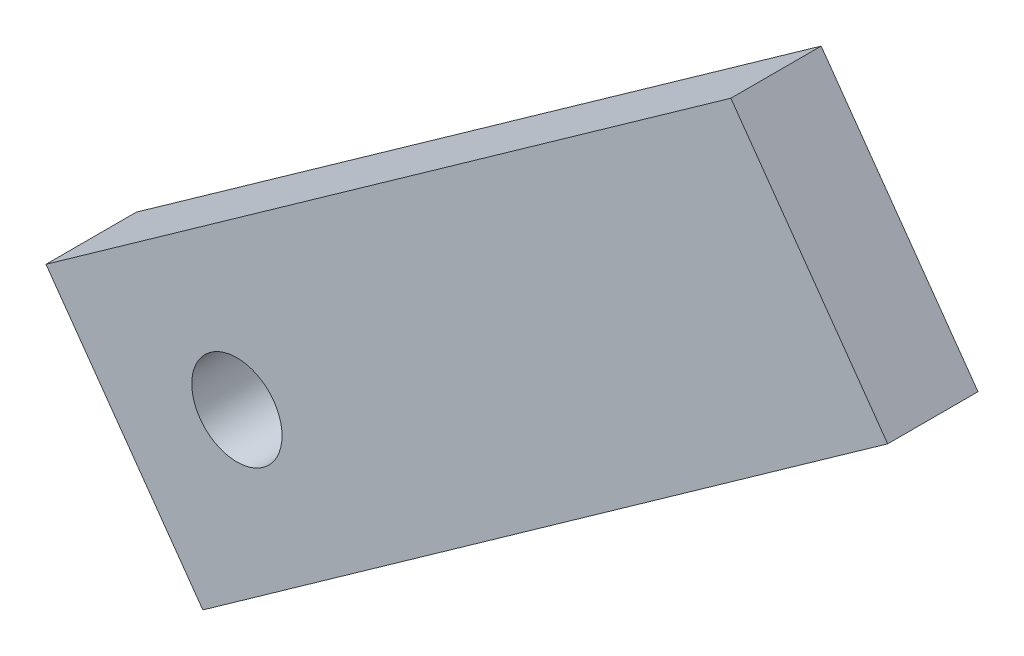
from build123d import *

# Parameters (mm, degrees)
BOSS_EXTRUDE2_DEPTH = 2.54


with BuildPart() as part:
    # Sketch1 → Boss-Extrude2 (new body)
    with BuildSketch(Plane.XY):
        with BuildLine():
            Line((-48.545691329, 22.127640633), (-64.643124973, 10.698462746))
            Line((-64.643124973, 10.698462746), (-63.172663299, 8.627389965))
            ThreePointArc((-63.172663299, 8.627389965), (-62.225084369, 8.843975089), (-61.401896071, 8.327084411))
            Line((-61.401896071, 8.327084411), (-46.339998817, 19.021031462))
            Line((-46.339998817, 19.021031462), (-48.545691329, 22.127640633))
        make_face()
        with BuildLine():
            Line((-44.134306305, 15.914422291), (-46.339998817, 19.021031462))
            Line((-46.339998817, 19.021031462), (-61.401896071, 8.327084411))
            ThreePointArc((-61.401896071, 8.327084411), (-61.227467335, 7.977708977), (-61.167432462, 7.591853574))
            ThreePointArc((-61.167432462, 7.591853574), (-61.309016943, 7.00912), (-61.702201624, 6.556317184))
            Line((-61.702201624, 6.556317184), (-60.23173995, 4.485244403))
            Line((-60.23173995, 4.485244403), (-44.134306305, 15.914422291))
        make_face()
        with BuildLine():
            Line((-63.472968852, 6.856622737), (-65.60097568, 5.345737889))
            Line((-65.60097568, 5.345737889), (-63.395283168, 2.239128718))
            Line((-63.395283168, 2.239128718), (-60.23173995, 4.485244403))
            Line((-60.23173995, 4.485244403), (-61.702201624, 6.556317184))
            ThreePointArc((-61.702201624, 6.556317184), (-62.649780555, 6.33973206), (-63.472968852, 6.856622737))
        make_face()
        with BuildLine():
            Line((-64.643124973, 10.698462746), (-67.806668191, 8.452347061))
            Line((-67.806668191, 8.452347061), (-65.60097568, 5.345737889))
            Line((-65.60097568, 5.345737889), (-63.472968852, 6.856622737))
            ThreePointArc((-63.472968852, 6.856622737), (-63.689553976, 7.804201667), (-63.172663299, 8.627389965))
            Line((-63.172663299, 8.627389965), (-64.643124973, 10.698462746))
        make_face()
    extrude(amount=BOSS_EXTRUDE2_DEPTH)


solid = part.part
